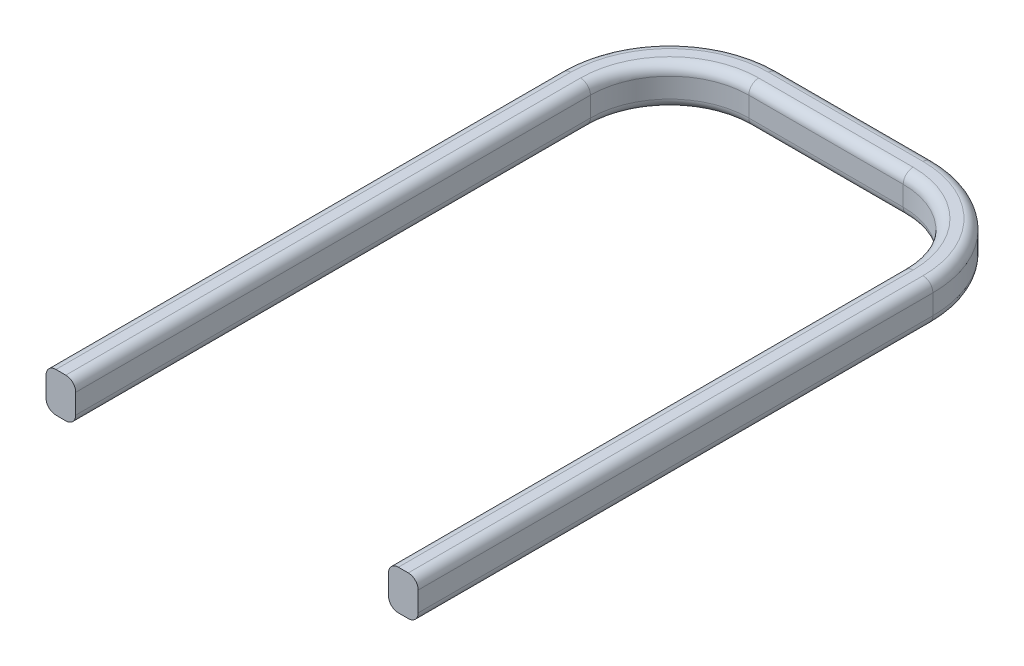
from build123d import *

# Parameters (mm, degrees)
BOSS_EXTRUDE1_DEPTH = 1
FILLET1_R           = 0.25


with BuildPart() as part:
    # Sketch1 → Boss-Extrude1 (new body)
    with BuildSketch(Plane(origin=(0, 0, 0), x_dir=(1, 0, 0), z_dir=(0, 1, 0))):
        with BuildLine():
            Line((-4.7, 5.5), (-4.7, -7.5))
            Line((-4.7, -7.5), (-3.95, -7.5))
            Line((-3.95, -7.5), (-3.95, 5.5))
            ThreePointArc((-3.95, 5.5), (-3.364213562, 6.914213562), (-1.95, 7.5))
            Line((-1.95, 7.5), (1.95, 7.5))
            ThreePointArc((1.95, 7.5), (3.364213562, 6.914213562), (3.95, 5.5))
            Line((3.95, 5.5), (3.95, -7.5))
            Line((3.95, -7.5), (4.7, -7.5))
            Line((4.7, -7.5), (4.7, 5.5))
            ThreePointArc((4.7, 5.5), (3.894543648, 7.444543648), (1.95, 8.25))
            Line((1.95, 8.25), (-1.95, 8.25))
            ThreePointArc((-1.95, 8.25), (-3.894543648, 7.444543648), (-4.7, 5.5))
        make_face()
    extrude(amount=BOSS_EXTRUDE1_DEPTH)

    # Fillet1
    fillet1_edges = [part.edges().sort_by_distance(p)[0] for p in [
        (3.95, 0, 1),
        (3.364213562, 0, -6.914213562),
        (3.894543648, 1, -7.444543648),
        (0, 0, -7.5),
        (-3.364213562, 0, -6.914213562),
        (-3.95, 0, 1),
        (-4.7, 0, 1),
        (-3.894543648, 0, -7.444543648),
        (0, 0, -8.25),
        (3.894543648, 0, -7.444543648),
        (4.7, 0, 1),
        (0, 1, -8.25),
        (-3.894543648, 1, -7.444543648),
        (-4.7, 1, 1),
        (-3.95, 1, 1),
        (-3.364213562, 1, -6.914213562),
        (0, 1, -7.5),
        (3.364213562, 1, -6.914213562),
        (3.95, 1, 1),
        (4.7, 1, 1),
    ]]
    fillet(fillet1_edges, radius=FILLET1_R)


solid = part.part
